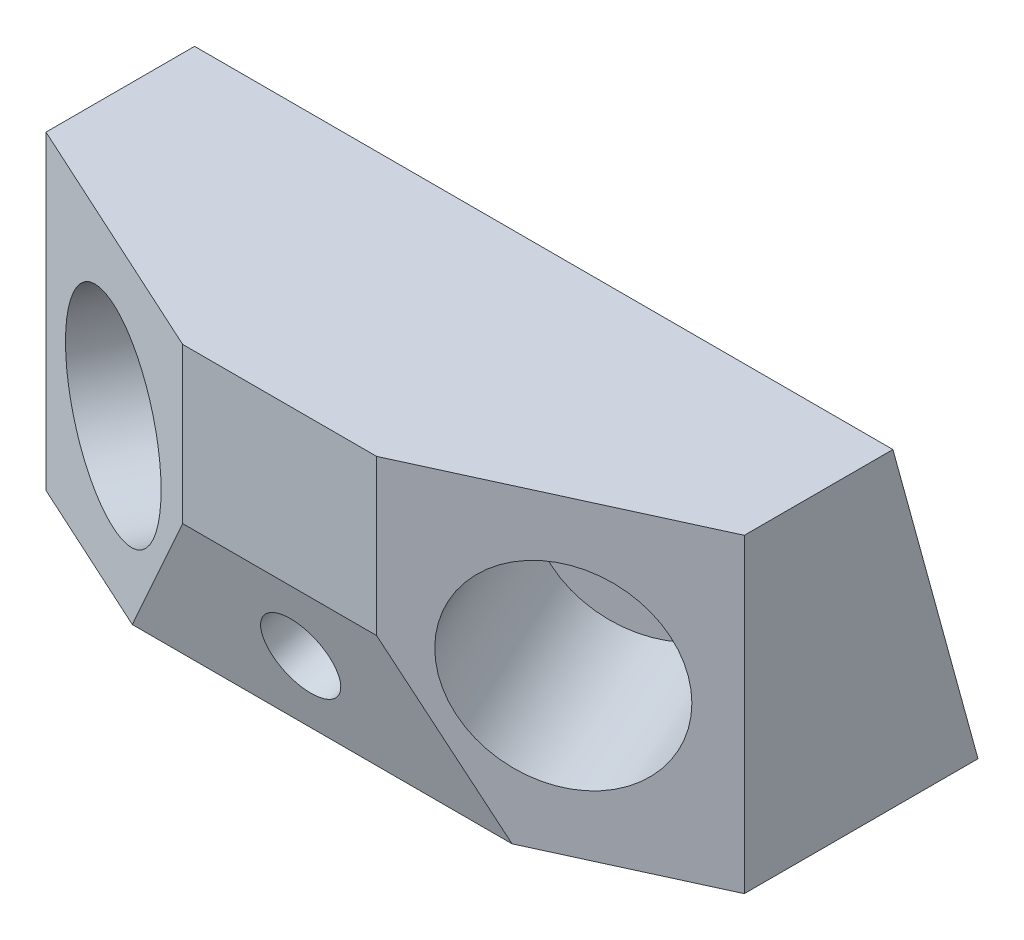
from build123d import *

# Parameters (mm, degrees)
ESQUISSE1_W             = 90
ESQUISSE1_H             = 40
BOSS_EXTRU_1_DEPTH      = 45
ENL_V_MAT_EXTRU_2_DEPTH = 45
ENL_V_MAT_EXTRU_3_DEPTH = 106
ESQUISSE6_R             = 12.5
ENL_V_MAT_EXTRU_4_DEPTH = 25
ESQUISSE7_R             = 5
ENL_V_MAT_EXTRU_5_DEPTH = 56
ESQUISSE9_R             = 2
ENL_V_MAT_EXTRU_6_DEPTH = 11


with BuildPart() as part:
    # Esquisse1 → Boss.-Extru.1 (new body)
    with BuildSketch(Plane.XY):
        Rectangle(ESQUISSE1_W, ESQUISSE1_H)
    extrude(amount=BOSS_EXTRU_1_DEPTH)

    # Esquisse2 → Enlèv. mat.-Extru.2 (cut)
    with BuildSketch(Plane.XZ.offset(20)):
        Polygon((45, 45), (12.5, 45), (45, 30.113476392), align=None)
        Polygon((-45, 30.113476392), (-12.5, 45), (-45, 45), align=None)
    extrude(amount=-ENL_V_MAT_EXTRU_2_DEPTH, mode=Mode.SUBTRACT)

    # Esquisse3 → Enlèv. mat.-Extru.3 (cut)
    with BuildSketch(Plane(origin=(45, 0, 0), x_dir=(0, 0, -1), z_dir=(1, 0, 0))):
        Polygon((0, -20), (-10.965276347, 20), (0, 20), align=None)
        Polygon((-45, 0), (-39.517361826, -20), (-45, -20), align=None)
    extrude(amount=-ENL_V_MAT_EXTRU_3_DEPTH, mode=Mode.SUBTRACT)

    # Esquisse6 → Enlèv. mat.-Extru.4 (cut)
    with BuildSketch(Plane(origin=(19.205292649, 0, 41.928661621), x_dir=(0.90916344, 0, -0.416439478), z_dir=(0.416439478, 0, 0.90916344))):
        with Locations((10.771914446, 0)):
            Circle(ESQUISSE6_R)
    enl_v_mat_extru_4 = extrude(amount=-ENL_V_MAT_EXTRU_4_DEPTH, mode=Mode.SUBTRACT)

    # Symétrie1: Enlèv. mat.-Extru.4 across plane
    add(enl_v_mat_extru_4.mirror(Plane(origin=(0, 0, 0), x_dir=(0, 0, 1), z_dir=(1, 0, 0))), mode=Mode.SUBTRACT)

    # Esquisse7 → Enlèv. mat.-Extru.5 (cut)
    with BuildSketch(Plane(origin=(0, -11.473706327, 41.854690985), x_dir=(1, 0, 0), z_dir=(0, -0.264378055, 0.964419123))):
        with Locations((0, 1.6591408)):
            Circle(ESQUISSE7_R)
    extrude(amount=-ENL_V_MAT_EXTRU_5_DEPTH, mode=Mode.SUBTRACT)

    # Esquisse9 → Enlèv. mat.-Extru.6 (cut)
    with BuildSketch(Plane(origin=(0, -1.397915118, 5.099425034), x_dir=(-1, 0, 0), z_dir=(0, 0.264378055, -0.964419123))):
        with Locations((35, 1.496078457)):
            Circle(ESQUISSE9_R)
        with Locations((-35, 1.822203143)):
            Circle(ESQUISSE9_R)
    extrude(amount=-ENL_V_MAT_EXTRU_6_DEPTH, mode=Mode.SUBTRACT)


solid = part.part
